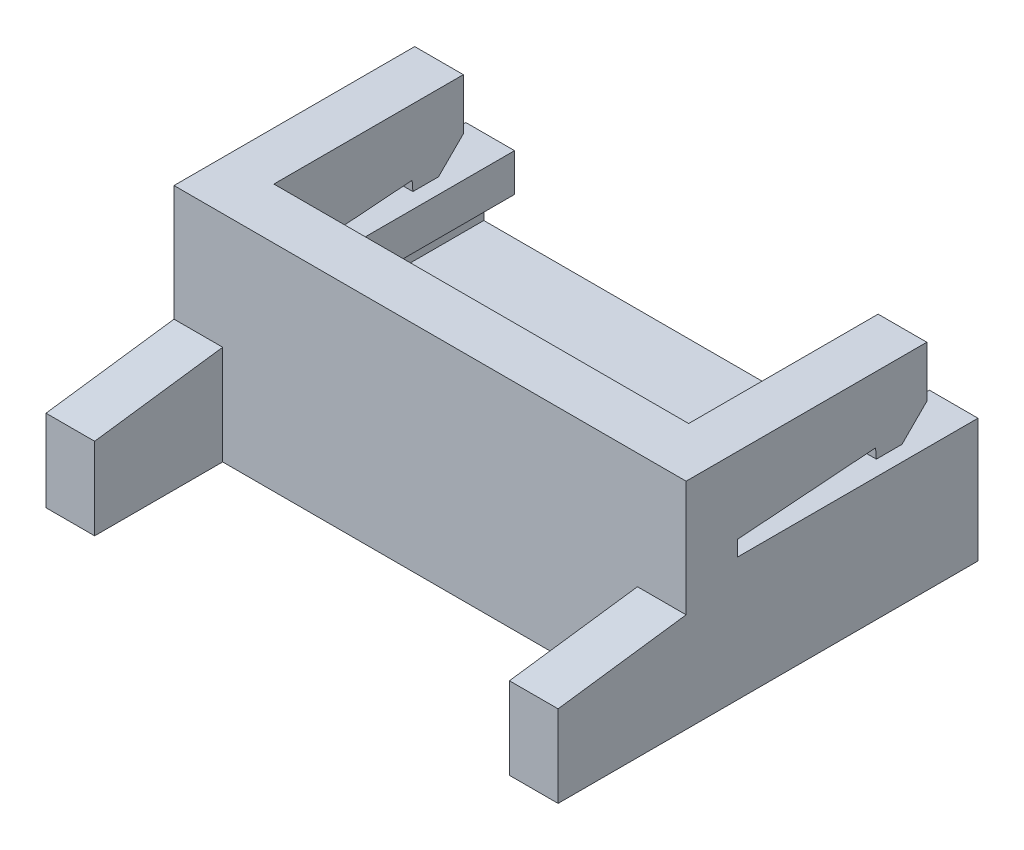
from build123d import *

# Parameters (mm, degrees)
SKETCH1_W           = 10
SKETCH1_H           = 8.2
BOSS_EXTRUDE1_DEPTH = 4.2
CUT_EXTRUDE1_DEPTH  = 10
CUT_EXTRUDE2_DEPTH  = 10
CUT_EXTRUDE4_DEPTH  = 4.7
CUT_EXTRUDE5_REACH  = 6.2
SKETCH6_W           = 8.1
SKETCH6_H           = 2.5


with BuildPart() as part:
    # Sketch1 → Boss-Extrude1 (new body)
    with BuildSketch(Plane(origin=(0, 0, 0), x_dir=(1, 0, 0), z_dir=(0, 1, 0))):
        with Locations((5, -4.1)):
            Rectangle(SKETCH1_W, SKETCH1_H)
    extrude(amount=BOSS_EXTRUDE1_DEPTH)

    # Sketch2 → Cut-Extrude1 (cut)
    with BuildSketch(Plane.ZY):
        Polygon((8.2, 4.2), (8.2, 1.6), (5.7, 1.94), (5.7, 4.2), align=None)
    extrude(amount=-CUT_EXTRUDE1_DEPTH, mode=Mode.SUBTRACT)

    # Sketch3 → Cut-Extrude2 (cut)
    with BuildSketch(Plane.ZY):
        Polygon((0, 2.414814815), (4.7, 2.414814815), (4.7, 2.714814815), (2, 2.914814815), (1.985185185, 2.714814815), (1.485185185, 2.714814815), (1, 3.2), (1, 4.2), (0, 4.2), align=None)
    extrude(amount=-CUT_EXTRUDE2_DEPTH, mode=Mode.SUBTRACT)

    # Sketch4 → Cut-Extrude4 (cut)
    with BuildSketch(Plane(origin=(0, 0, 0), x_dir=(-1, 0, 0), z_dir=(0, 0, -1))):
        Polygon((-9.65, 0.93347747), (-9.65, 1.674146142), (-9.05, 1.674146142), (-9.05, 4.2), (-0.95, 4.2), (-0.95, 1.674146142), (-0.35, 1.674146142), (-0.35, 0.93347747), align=None)
    extrude(amount=-CUT_EXTRUDE4_DEPTH, mode=Mode.SUBTRACT)

    # Cut-Extrude5: up to this face of the body (flat: up to its plane)
    cut_extrude5_end = Plane(part.part.faces().sort_by_distance((5, 1.77, 6.95))[0])
    # Sketch6 → Cut-Extrude5 (cut, up to the picked face)
    with BuildSketch(Plane.XZ, mode=Mode.PRIVATE) as cut_extrude5_sk1:
        with Locations((5, 6.95)):
            Rectangle(SKETCH6_W, SKETCH6_H)
    cut_extrude5_tool1 = split(extrude(cut_extrude5_sk1.sketch, amount=-CUT_EXTRUDE5_REACH, mode=Mode.PRIVATE), bisect_by=cut_extrude5_end, keep=Keep.BOTH, mode=Mode.PRIVATE)
    add(cut_extrude5_tool1.solids().sort_by_distance((5, 0, 6.95))[0], mode=Mode.SUBTRACT)


solid = part.part
